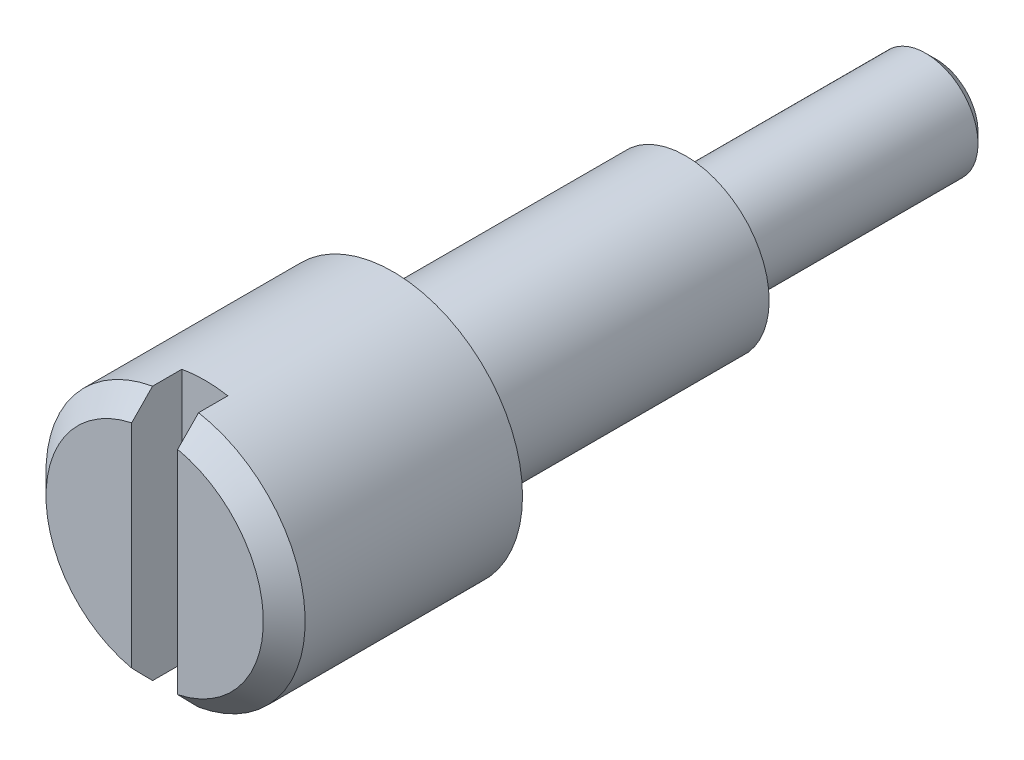
from build123d import *

# Parameters (mm, degrees)
SKETCH_1_R          = 3.1
EXTRUDE_1_DEPTH     = 5.7
SKETCH_2_R          = 2
EXTRUDE_2_DEPTH     = 7
SKETCH_3_R          = 1.25
EXTRUDE_3_DEPTH     = 6
CHAMFER_1_SIZE      = 0.2535
CHAMFER_2_SIZE      = 0.5
SKETCH_5_W          = 1.1
SKETCH_5_H          = 7
CUT_EXTRUDE_1_DEPTH = 1.2


with BuildPart() as part:
    # Эскиз1 → Бобышка-Вытянуть1 (new body)
    with BuildSketch(Plane.XY):
        Circle(SKETCH_1_R)
    extrude(amount=EXTRUDE_1_DEPTH)

    # Эскиз2 → Бобышка-Вытянуть2 (add)
    with BuildSketch(Plane(origin=(0, 0, 0), x_dir=(-1, 0, 0), z_dir=(0, 0, -1))):
        Circle(SKETCH_2_R)
    extrude(amount=EXTRUDE_2_DEPTH)

    # Эскиз3 → Бобышка-Вытянуть3 (add)
    with BuildSketch(Plane(origin=(0, 0, -7), x_dir=(-1, 0, 0), z_dir=(0, 0, -1))):
        Circle(SKETCH_3_R)
    extrude(amount=EXTRUDE_3_DEPTH)

    # Фаска1
    chamfer_1_edges = [part.edges().sort_by_distance(p)[0] for p in [
        (1.25, 0, -13),
    ]]
    chamfer(chamfer_1_edges, length=CHAMFER_1_SIZE)

    # Фаска2
    chamfer_2_edges = [part.edges().sort_by_distance(p)[0] for p in [
        (-3.1, 0, 5.7),
    ]]
    chamfer(chamfer_2_edges, length=CHAMFER_2_SIZE)

    # Эскиз5 → Вырез-Вытянуть1 (cut)
    with BuildSketch(Plane.XY.offset(5.7)):
        Rectangle(SKETCH_5_W, SKETCH_5_H)
    extrude(amount=-CUT_EXTRUDE_1_DEPTH, mode=Mode.SUBTRACT)


solid = part.part
